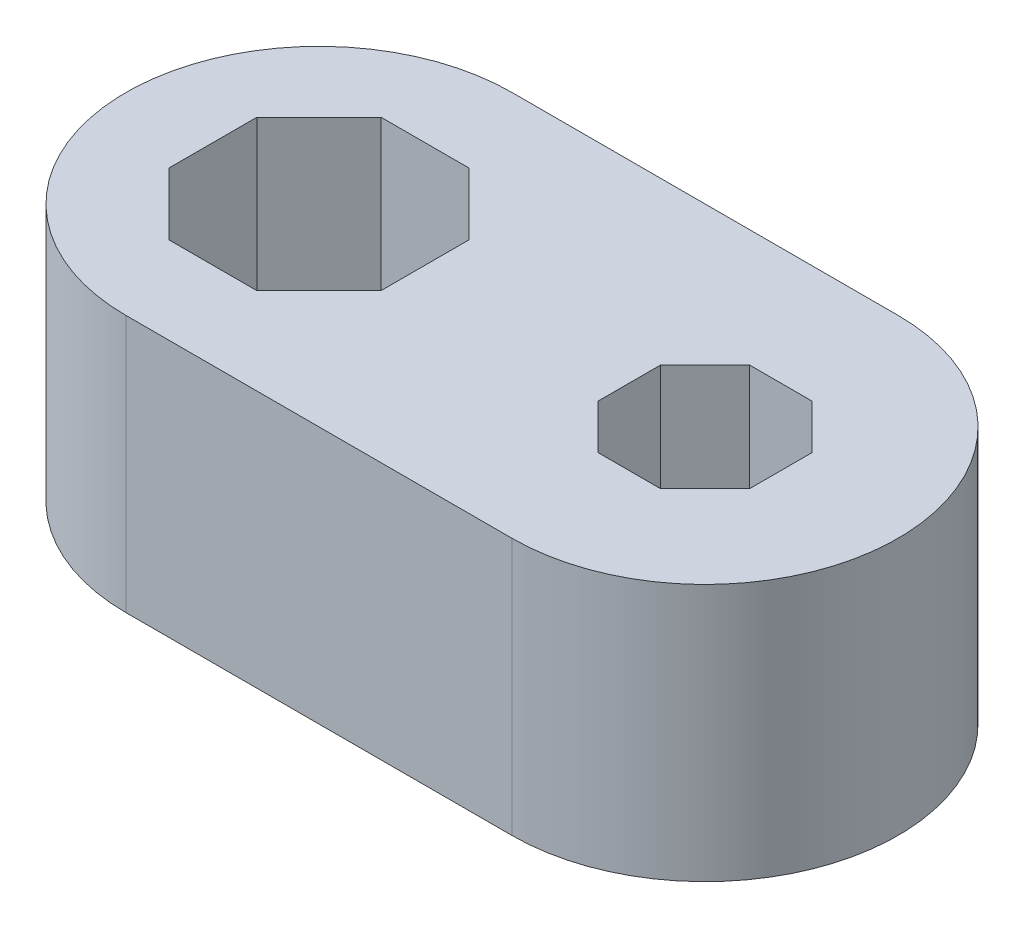
from build123d import *

# Parameters (mm, degrees)
BOSS_EXTRUDE1_DEPTH = 8


with BuildPart() as part:
    # Sketch1 → Boss-Extrude1 (new body)
    with BuildSketch(Plane(origin=(0, 0, 0), x_dir=(1, 0, 0), z_dir=(0, 1, 0))):
        with BuildLine():
            Line((-6, 6), (6, 6))
            ThreePointArc((6, 6), (12, 0), (6, -6))
            Line((6, -6), (-6, -6))
            ThreePointArc((-6, -6), (-12, 0), (-6, 6))
        make_face()
        Polygon((-4.63382, 3.298250285), (-7.36618, 3.298250285), (-9.298250285, 1.36618), (-9.298250285, -1.36618), (-7.36618, -3.298250285), (-4.63382, -3.298250285), (-2.701749715, -1.36618), (-2.701749715, 1.36618), align=None, mode=Mode.SUBTRACT)
        Polygon((8.355898234, 0.975845), (6.975845, 2.355898234), (5.024155, 2.355898234), (3.644101766, 0.975845), (3.644101766, -0.975845), (5.024155, -2.355898234), (6.975845, -2.355898234), (8.355898234, -0.975845), align=None, mode=Mode.SUBTRACT)
    extrude(amount=BOSS_EXTRUDE1_DEPTH)


solid = part.part
